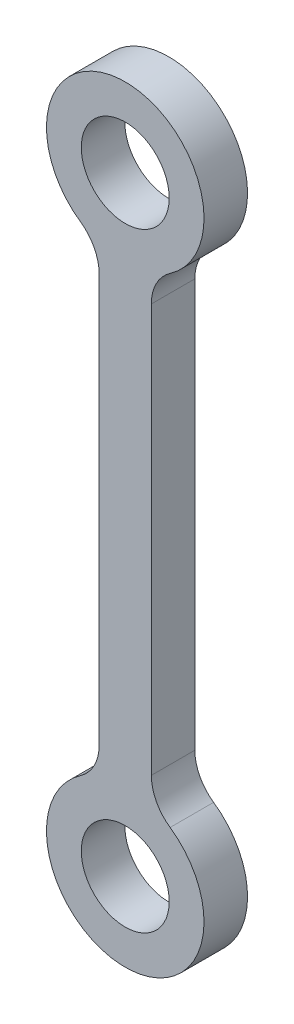
from build123d import *

# Parameters (mm, degrees)
ESQUISSE1_R        = 6.4135
BOSS_EXTRU_1_DEPTH = 6.35


with BuildPart() as part:
    # Esquisse1 → Boss.-Extru.1 (new body)
    with BuildSketch(Plane.XY):
        with BuildLine():
            Line((-3.81, -14.6685), (-3.81, -74.2315))
            ThreePointArc((-3.81, -74.2315), (-4.534969751, -77.177944416), (-6.544341637, -79.451606762))
            ThreePointArc((-6.544341637, -79.451606762), (0, -100.3935), (6.544341637, -79.451606762))
            ThreePointArc((6.544341637, -79.451606762), (4.534969751, -77.177944416), (3.81, -74.2315))
            Line((3.81, -74.2315), (3.81, -14.6685))
            ThreePointArc((3.81, -14.6685), (4.534969751, -11.722055584), (6.544341637, -9.448393238))
            ThreePointArc((6.544341637, -9.448393238), (0, 11.4935), (-6.544341637, -9.448393238))
            ThreePointArc((-6.544341637, -9.448393238), (-4.534969751, -11.722055584), (-3.81, -14.6685))
        make_face()
        Circle(ESQUISSE1_R, mode=Mode.SUBTRACT)
        with Locations((0, -88.9)):
            Circle(ESQUISSE1_R, mode=Mode.SUBTRACT)
    extrude(amount=BOSS_EXTRU_1_DEPTH)


solid = part.part
